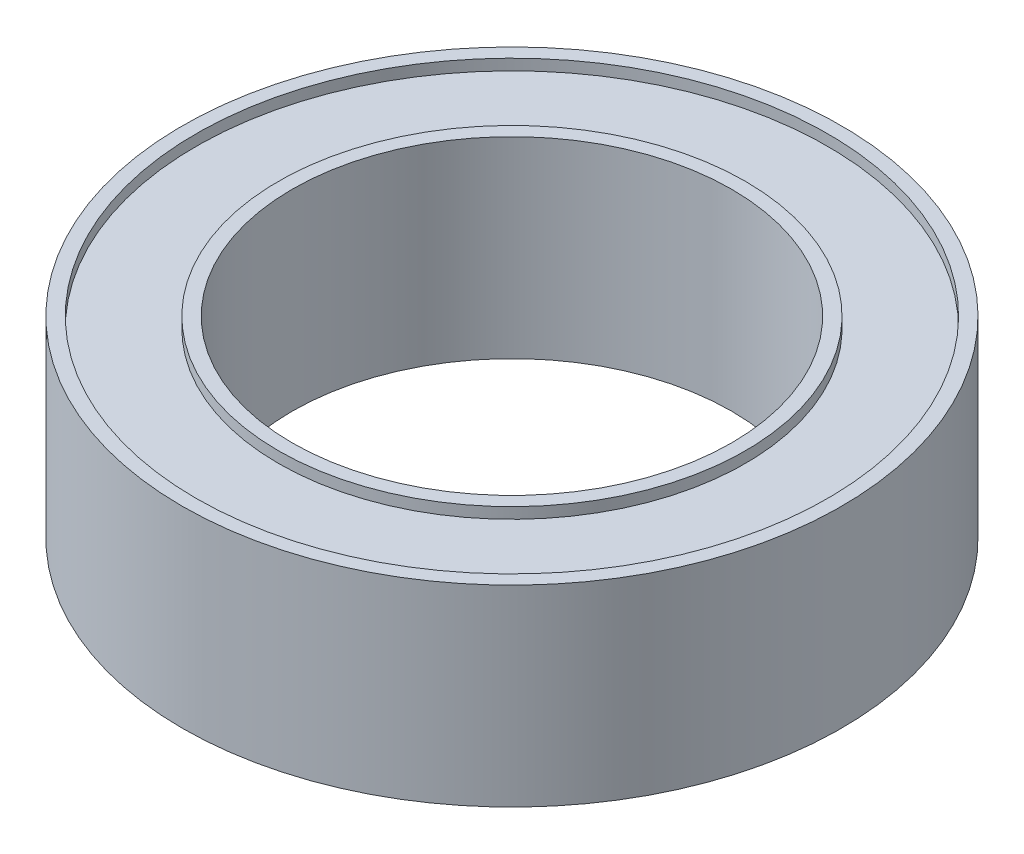
from build123d import *

# Parameters (mm, degrees)
SKETCH1_R           = 6
SKETCH1_R_2         = 4
BOSS_EXTRUDE1_DEPTH = 3.5
SKETCH2_R           = 5.75
SKETCH2_R_2         = 4.25
CUT_EXTRUDE1_DEPTH  = 0.2
CUT_EXTRUDE2_START  = -3.5
SKETCH2_2_R         = 5.75
SKETCH2_2_R_2       = 4.25
CUT_EXTRUDE2_DEPTH  = 0.2


with BuildPart() as part:
    # Sketch1 → Boss-Extrude1 (new body)
    with BuildSketch(Plane(origin=(0, 0, 0), x_dir=(1, 0, 0), z_dir=(0, 1, 0))):
        Circle(SKETCH1_R)
        Circle(SKETCH1_R_2, mode=Mode.SUBTRACT)
    extrude(amount=BOSS_EXTRUDE1_DEPTH)

    # Sketch2 → Cut-Extrude1 (cut)
    with BuildSketch(Plane(origin=(0, 3.5, 0), x_dir=(1, 0, 0), z_dir=(0, 1, 0))):
        Circle(SKETCH2_R)
        Circle(SKETCH2_R_2, mode=Mode.SUBTRACT)
    extrude(amount=-CUT_EXTRUDE1_DEPTH, mode=Mode.SUBTRACT)

    # Sketch2_2 → Cut-Extrude2 (cut)
    with BuildSketch(Plane(origin=(0, 3.5, 0), x_dir=(1, 0, 0), z_dir=(0, 1, 0)).offset(CUT_EXTRUDE2_START)):
        Circle(SKETCH2_2_R)
        Circle(SKETCH2_2_R_2, mode=Mode.SUBTRACT)
    extrude(amount=CUT_EXTRUDE2_DEPTH, mode=Mode.SUBTRACT)


solid = part.part
